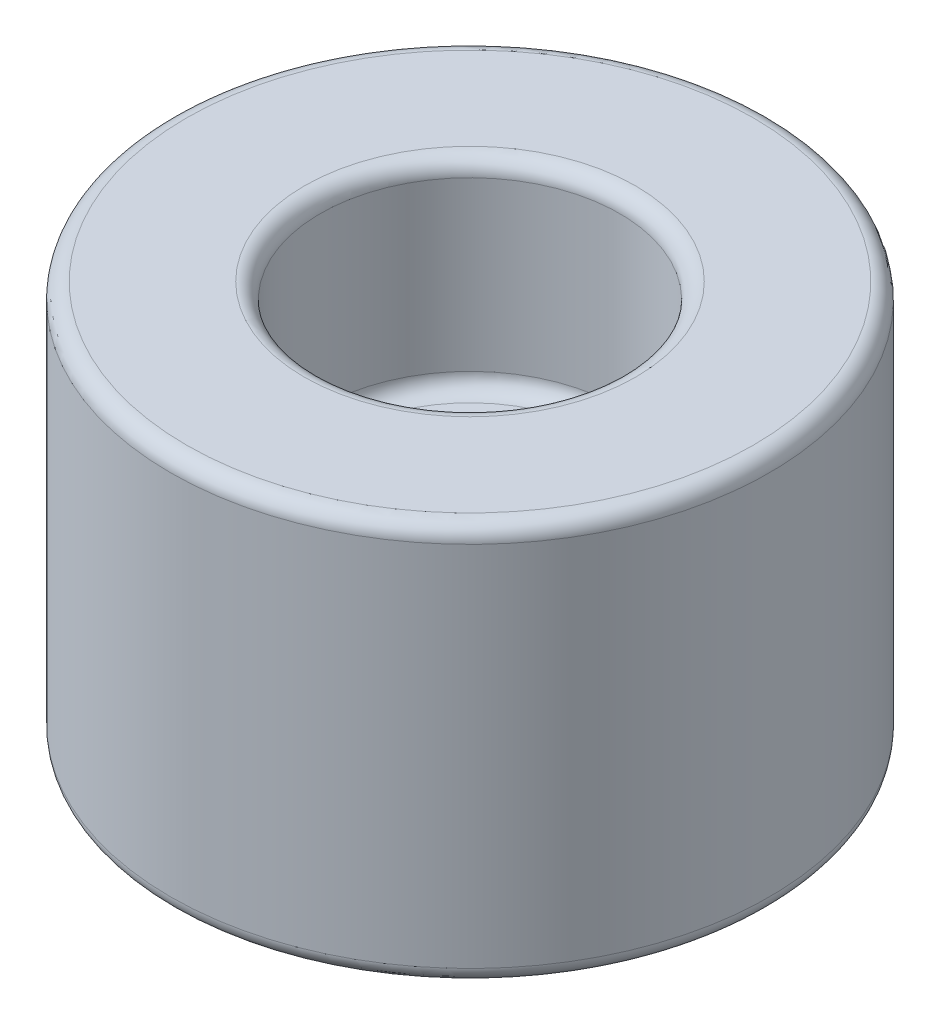
from build123d import *

# Parameters (mm, degrees)
FILLET1_R = 0.508


with BuildPart() as part:
    # Sketch1 → Revolve1 (revolve)
    with BuildSketch(Plane(origin=(0, 0, 0), x_dir=(0, 0, -1), z_dir=(1, 0, 0))):
        Polygon((1.7859375, 6.35), (4.7625, 6.35), (4.7625, 12.7), (9.525, 12.7), (9.525, 0), (1.7859375, 0), align=None)
    revolve(axis=Axis((0, 0, 0), (0, 1, 0)))

    # Fillet1
    fillet1_edges = [part.edges().sort_by_distance(p)[0] for p in [
        (0, 6.35, 4.7625),
        (0, 6.35, 1.7859375),
        (0, 0, 1.7859375),
        (0, 0, 9.525),
        (0, 12.7, 9.525),
        (0, 12.7, 4.7625),
    ]]
    fillet(fillet1_edges, radius=FILLET1_R)


solid = part.part
